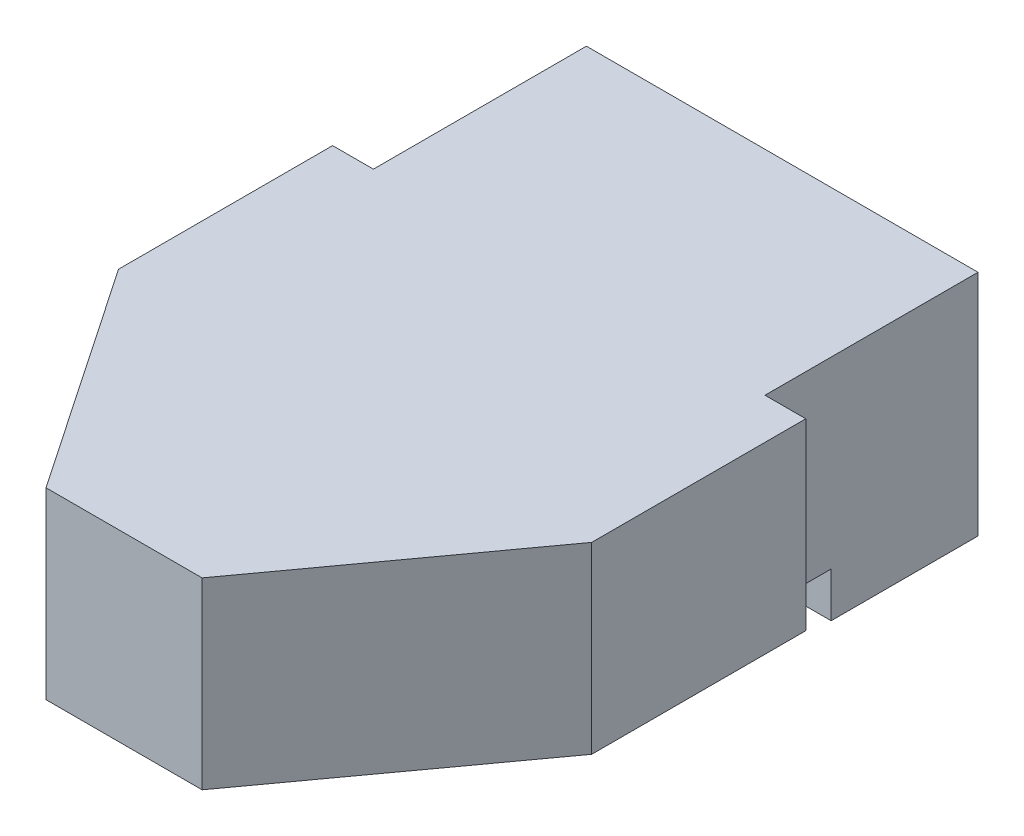
from build123d import *

# Parameters (mm, degrees)
BOSS_EXTRUDE1_DEPTH = 14
SKETCH2_R           = 2.25
BOSS_EXTRUDE2_DEPTH = 2.75
SKETCH4_R           = 2.25
CUT_EXTRUDE1_DEPTH  = 2.75


with BuildPart() as part:
    # Sketch1 → Boss-Extrude1 (new body)
    with BuildSketch(Plane(origin=(0, 0, 0), x_dir=(1, 0, 0), z_dir=(0, 1, 0))):
        Polygon((8.692930554, 39.050653624), (32.692930554, 39.050653624), (32.692930554, 25.995392605), (35.192930554, 25.995392605), (35.192930554, 12.875501581), (25.138333129, -0.949346376), (15.571219536, -0.949346376), (6.192930554, 12.875501581), (6.192930554, 25.995392605), (8.692930554, 25.995392605), align=None)
    extrude(amount=BOSS_EXTRUDE1_DEPTH)

    # Sketch2 → Boss-Extrude2 (add)
    with BuildSketch(Plane.XZ):
        with Locations(Location((20.5, -18, 0), (0, 0, 270))):
            Circle(SKETCH2_R)
    extrude(amount=BOSS_EXTRUDE2_DEPTH)

    # Sketch4 → Cut-Extrude1 (cut)
    with BuildSketch(Plane(origin=(0, 0, 0), x_dir=(-1, 0, 0), z_dir=(0, -1, 0))):
        Polygon((-8.692930554, 30.050653624), (-8.692930554, 25.995392605), (-6.192930554, 25.995392605), (-6.192930554, 12.875501581), (-15.571219536, -0.949346376), (-25.138333129, -0.949346376), (-35.192930554, 12.875501581), (-35.192930554, 25.995392605), (-32.692930554, 25.995392605), (-32.692930554, 30.050653624), align=None)
        with Locations(Location((-20.5, 18, 0), (0, 0, 90))):
            Circle(SKETCH4_R, mode=Mode.SUBTRACT)
    extrude(amount=-CUT_EXTRUDE1_DEPTH, mode=Mode.SUBTRACT)


solid = part.part
